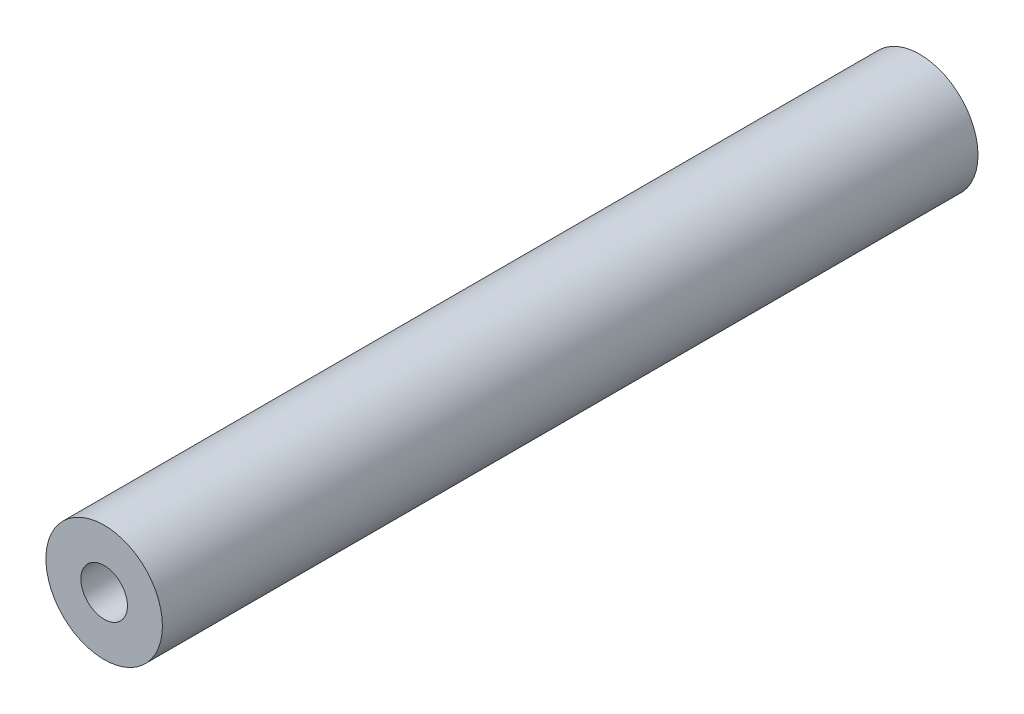
from build123d import *

# Parameters (mm, degrees)
SKETCH1_R           = 5
SKETCH1_R_2         = 2
BOSS_EXTRUDE1_DEPTH = 70


with BuildPart() as part:
    # Sketch1 → Boss-Extrude1 (new body)
    with BuildSketch(Plane.XY):
        Circle(SKETCH1_R)
        Circle(SKETCH1_R_2, mode=Mode.SUBTRACT)
    extrude(amount=BOSS_EXTRUDE1_DEPTH)


solid = part.part
